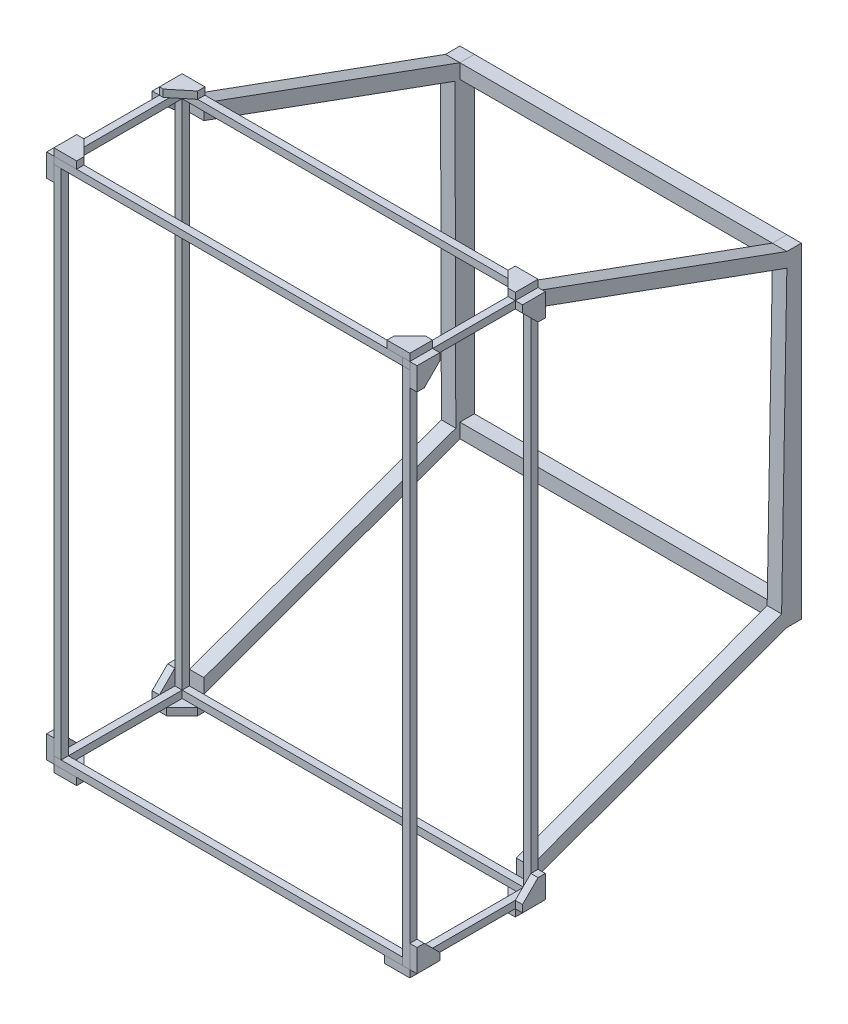
from build123d import *

# Parameters (mm, degrees)
SKETCH1_W                 = 6.35
SKETCH1_H                 = 6.35
BOSS_EXTRUDE1_DEPTH       = 100
SKETCH4_W                 = 6.35
SKETCH4_H                 = 6.35
BOSS_EXTRUDE3_DEPTH       = 450
BOSS_EXTRUDE3_DEPTH_BACK  = 6.35
SKETCH6_W                 = 6.35
SKETCH6_H                 = 6.378778746
BOSS_EXTRUDE4_DEPTH       = 100
SKETCH7_W                 = 6.35
SKETCH7_H                 = 6.35
BOSS_EXTRUDE5_DEPTH       = 300
BOSS_EXTRUDE5_DEPTH_BACK  = 6.35
SKETCH8_W                 = 6.35
SKETCH8_H                 = 6.378778746
BOSS_EXTRUDE6_DEPTH       = 300
BOSS_EXTRUDE6_DEPTH_BACK  = 6.35
SKETCH10_W                = 6.35
SKETCH10_H                = 6.35
BOSS_EXTRUDE7_DEPTH       = 450
BOSS_EXTRUDE7_DEPTH_BACK  = 6.378779
SKETCH12_W                = 6.35
SKETCH12_H                = 6.35
BOSS_EXTRUDE8_DEPTH       = 450
BOSS_EXTRUDE8_DEPTH_BACK  = 6.35
SKETCH16_W                = 6.35
SKETCH16_H                = 6.35
BOSS_EXTRUDE9_DEPTH       = 100
SKETCH20_W                = 6.35
SKETCH20_H                = 6.35
BOSS_EXTRUDE10_DEPTH      = 100
BOSS_EXTRUDE10_DEPTH_BACK = 6.35
SKETCH21_W                = 6.35
SKETCH21_H                = 6.378778746
BOSS_EXTRUDE11_DEPTH      = 300
BOSS_EXTRUDE11_DEPTH_BACK = 6.35
SKETCH22_W                = 6.35
SKETCH22_H                = 6.35
BOSS_EXTRUDE12_DEPTH      = 450
BOSS_EXTRUDE12_DEPTH_BACK = 6.35
SKETCH23_W                = 6.35
SKETCH23_H                = 6.35
BOSS_EXTRUDE13_DEPTH      = 300
BOSS_EXTRUDE13_DEPTH_BACK = 6.35
BOSS_EXTRUDE20_DEPTH      = 12.7
BOSS_EXTRUDE21_DEPTH      = 12.7
BOSS_EXTRUDE22_DEPTH      = 12.7
BOSS_EXTRUDE23_DEPTH      = 12.7
BOSS_EXTRUDE24_DEPTH      = 12.7
BOSS_EXTRUDE25_DEPTH      = 12.7
BOSS_EXTRUDE29_DEPTH      = 6.35
BOSS_EXTRUDE30_DEPTH      = 6.35
BOSS_EXTRUDE31_DEPTH      = 6.35
BOSS_EXTRUDE32_DEPTH      = 6.35
BOSS_EXTRUDE33_DEPTH      = 6.35
BOSS_EXTRUDE34_DEPTH      = 6.35
BOSS_EXTRUDE35_DEPTH      = 6.35
BOSS_EXTRUDE36_DEPTH      = 6.35
BOSS_EXTRUDE37_DEPTH      = 6.35
BOSS_EXTRUDE37_2_DEPTH    = 6.35
BOSS_EXTRUDE37_3_DEPTH    = 6.35
BOSS_EXTRUDE37_4_DEPTH    = 6.35
BOSS_EXTRUDE38_DEPTH      = 6.35
BOSS_EXTRUDE38_2_DEPTH    = 6.35
BOSS_EXTRUDE38_3_DEPTH    = 6.35
BOSS_EXTRUDE38_4_DEPTH    = 6.35
SKETCH43_W                = 274.6
SKETCH43_H                = 12.7
BOSS_EXTRUDE40_DEPTH      = 12.7
SKETCH44_W                = 274.6
SKETCH44_H                = 12.7
BOSS_EXTRUDE41_DEPTH      = 12.7


with BuildPart() as part:
    # Sketch1 → Boss-Extrude1 (new body)
    with BuildSketch(Plane.XY):
        with Locations((3.175, 3.175)):
            Rectangle(SKETCH1_W, SKETCH1_H)
    extrude(amount=BOSS_EXTRUDE1_DEPTH)


with BuildPart() as body_2:
    # Sketch4 → Boss-Extrude3 (new body, two sides)
    with BuildSketch(Plane(origin=(0, 0, 0), x_dir=(-1, 0, 0), z_dir=(0, -1, 0))) as boss_extrude3_sk:
        with Locations((-3.175, -103.175)):
            Rectangle(SKETCH4_W, SKETCH4_H)
    extrude(amount=BOSS_EXTRUDE3_DEPTH)
    extrude(boss_extrude3_sk.sketch, amount=-BOSS_EXTRUDE3_DEPTH_BACK)


with BuildPart() as body_3:
    # Sketch6 → Boss-Extrude4 (new body)
    with BuildSketch(Plane(origin=(0, 0, 100), x_dir=(-1, 0, 0), z_dir=(0, 0, -1))):
        with Locations((-3.175, -453.189389373)):
            Rectangle(SKETCH6_W, SKETCH6_H)
    extrude(amount=BOSS_EXTRUDE4_DEPTH)


with BuildPart() as body_4:
    # Sketch7 → Boss-Extrude5 (new body, two sides)
    with BuildSketch(Plane(origin=(6.35, 0, 0), x_dir=(0, 0, -1), z_dir=(1, 0, 0))) as boss_extrude5_sk:
        with Locations((-103.175, 3.175)):
            Rectangle(SKETCH7_W, SKETCH7_H)
    extrude(amount=BOSS_EXTRUDE5_DEPTH)
    extrude(boss_extrude5_sk.sketch, amount=-BOSS_EXTRUDE5_DEPTH_BACK)


with BuildPart() as body_5:
    # Sketch8 → Boss-Extrude6 (new body, two sides)
    with BuildSketch(Plane(origin=(6.35, 0, 0), x_dir=(0, 0, -1), z_dir=(1, 0, 0))) as boss_extrude6_sk:
        with Locations((-103.175, -453.189389373)):
            Rectangle(SKETCH8_W, SKETCH8_H)
    extrude(amount=BOSS_EXTRUDE6_DEPTH)
    extrude(boss_extrude6_sk.sketch, amount=-BOSS_EXTRUDE6_DEPTH_BACK)


with BuildPart() as body_6:
    # Sketch10 → Boss-Extrude7 (new body, two sides)
    with BuildSketch(Plane(origin=(0, -450, 0), x_dir=(1, 0, 0), z_dir=(0, 1, 0))) as boss_extrude7_sk:
        with Locations((309.525, -103.175)):
            Rectangle(SKETCH10_W, SKETCH10_H)
    extrude(amount=BOSS_EXTRUDE7_DEPTH)
    extrude(boss_extrude7_sk.sketch, amount=-BOSS_EXTRUDE7_DEPTH_BACK)


with BuildPart() as body_7:
    # Sketch12 → Boss-Extrude8 (new body, two sides)
    with BuildSketch(Plane(origin=(0, 0, 0), x_dir=(-1, 0, 0), z_dir=(0, -1, 0))) as boss_extrude8_sk:
        with Locations((-3.175, 3.175)):
            Rectangle(SKETCH12_W, SKETCH12_H)
    extrude(amount=BOSS_EXTRUDE8_DEPTH)
    extrude(boss_extrude8_sk.sketch, amount=-BOSS_EXTRUDE8_DEPTH_BACK)


with BuildPart() as body_8:
    # Sketch16 → Boss-Extrude9 (new body)
    with BuildSketch(Plane(origin=(0, 0, 100), x_dir=(-1, 0, 0), z_dir=(0, 0, -1))):
        with Locations((-309.525, -453.175)):
            Rectangle(SKETCH16_W, SKETCH16_H)
    extrude(amount=BOSS_EXTRUDE9_DEPTH)


with BuildPart() as body_9:
    # Sketch20 → Boss-Extrude10 (new body, two sides)
    with BuildSketch(Plane(origin=(0, 0, 100), x_dir=(-1, 0, 0), z_dir=(0, 0, -1))) as boss_extrude10_sk:
        with Locations((-309.525, 3.175)):
            Rectangle(SKETCH20_W, SKETCH20_H)
    extrude(amount=BOSS_EXTRUDE10_DEPTH)
    extrude(boss_extrude10_sk.sketch, amount=-BOSS_EXTRUDE10_DEPTH_BACK)


with BuildPart() as body_10:
    # Sketch21 → Boss-Extrude11 (new body, two sides)
    with BuildSketch(Plane(origin=(6.35, 0, 0), x_dir=(0, 0, -1), z_dir=(1, 0, 0))) as boss_extrude11_sk:
        with Locations((3.175, -453.189389373)):
            Rectangle(SKETCH21_W, SKETCH21_H)
    extrude(amount=BOSS_EXTRUDE11_DEPTH)
    extrude(boss_extrude11_sk.sketch, amount=-BOSS_EXTRUDE11_DEPTH_BACK)


with BuildPart() as body_11:
    # Sketch22 → Boss-Extrude12 (new body, two sides)
    with BuildSketch(Plane(origin=(0, -450, 0), x_dir=(1, 0, 0), z_dir=(0, 1, 0))) as boss_extrude12_sk:
        with Locations((309.525, 3.175)):
            Rectangle(SKETCH22_W, SKETCH22_H)
    extrude(amount=BOSS_EXTRUDE12_DEPTH)
    extrude(boss_extrude12_sk.sketch, amount=-BOSS_EXTRUDE12_DEPTH_BACK)


with BuildPart() as body_12:
    # Sketch23 → Boss-Extrude13 (new body, two sides)
    with BuildSketch(Plane.ZY.offset(-306.35)) as boss_extrude13_sk:
        with Locations((-3.175, 3.175)):
            Rectangle(SKETCH23_W, SKETCH23_H)
    extrude(amount=BOSS_EXTRUDE13_DEPTH)
    extrude(boss_extrude13_sk.sketch, amount=-BOSS_EXTRUDE13_DEPTH_BACK)


with BuildPart() as body_13:
    # Sketch25 → Boss-Extrude20 (new body)
    with BuildSketch(Plane(origin=(6.35, 0, 0), x_dir=(0, 0, -1), z_dir=(1, 0, 0))):
        Polygon((6.35, 0), (231.35, -81.89330271), (227.00634418, -93.827398994), (6.35, -13.51505771), align=None)
    extrude(amount=BOSS_EXTRUDE20_DEPTH)



with BuildPart() as body_14:
    # Sketch26 → Boss-Extrude21 (new body)
    with BuildSketch(Plane.ZY.offset(-306.35)):
        Polygon((-6.35, 0), (-231.35, -81.89330271), (-231.35, -94.59330271), (-6.35, -12.7), align=None)
    extrude(amount=BOSS_EXTRUDE21_DEPTH)



with BuildPart() as body_15:
    # Sketch27 → Boss-Extrude22 (new body)
    with BuildSketch(Plane.ZY.offset(-306.35)):
        Polygon((-6.35, -450), (-231.35, -368.10669729), (-226.727578025, -355.40669729), (-6.35, -437.3), align=None)
    extrude(amount=BOSS_EXTRUDE22_DEPTH)


with BuildPart() as body_16:
    # Sketch28 → Boss-Extrude23 (new body)
    with BuildSketch(Plane(origin=(6.35, 0, 0), x_dir=(0, 0, -1), z_dir=(1, 0, 0))):
        Polygon((6.35, -450), (231.35, -368.10669729), (227.760753861, -358.24532457), (6.35, -437.3), align=None)
    extrude(amount=BOSS_EXTRUDE23_DEPTH)


with BuildPart() as body_14_1:
    add(body_14.part)

    add(body_15.part)  # Boss-Extrude24 merges body 15
    # Sketch29 → Boss-Extrude24 (add)
    with BuildSketch(Plane(origin=(306.35, 0, 0), x_dir=(0, 0, -1), z_dir=(1, 0, 0))):
        Polygon((231.35, -81.89330271), (231.35, -94.59330271), (226.727578025, -355.40669729), (231.35, -368.10669729), (244.05, -368.10669729), (244.05, -81.89330271), align=None)
    extrude(amount=-BOSS_EXTRUDE24_DEPTH)


with BuildPart() as body_13_1:
    add(body_13.part)

    add(body_16.part)  # Boss-Extrude25 merges body 16
    # Sketch31 → Boss-Extrude25 (add)
    with BuildSketch(Plane.ZY.offset(-6.35)):
        Polygon((-231.35, -81.89330271), (-227.00634418, -93.827398994), (-227.760753861, -358.24532457), (-231.35, -368.10669729), (-244.05, -368.10669729), (-244.05, -81.89330271), align=None)
    extrude(amount=-BOSS_EXTRUDE25_DEPTH)


with BuildPart() as body_15_2:
    # Sketch32 → Boss-Extrude29 (new body)
    with BuildSketch(Plane(origin=(312.7, 0, 0), x_dir=(0, 0, -1), z_dir=(1, 0, 0))):
        Polygon((-106.35, 6.35), (-106.35, -13.65), (-100, -13.65), (-86.35, 0), (-86.35, 6.35), align=None)
    extrude(amount=BOSS_EXTRUDE29_DEPTH)


with BuildPart() as body_16_2:
    # Sketch33 → Boss-Extrude30 (new body)
    with BuildSketch(Plane(origin=(312.7, 0, 0), x_dir=(0, 0, -1), z_dir=(1, 0, 0))):
        Polygon((-106.35, -456.378778746), (-106.35, -436.378778746), (-100, -436.378778746), (-86.35, -450), (-86.35, -456.35), align=None)
    extrude(amount=BOSS_EXTRUDE30_DEPTH)


with BuildPart() as body_17:
    # Sketch34 → Boss-Extrude31 (new body)
    with BuildSketch(Plane(origin=(312.7, 0, 0), x_dir=(0, 0, -1), z_dir=(1, 0, 0))):
        Polygon((6.35, 6.35), (-13.65, 6.35), (-13.65, 0), (0, -13.65), (6.35, -13.65), align=None)
    extrude(amount=BOSS_EXTRUDE31_DEPTH)


with BuildPart() as body_18:
    # Sketch35 → Boss-Extrude32 (new body)
    with BuildSketch(Plane(origin=(312.7, 0, 0), x_dir=(0, 0, -1), z_dir=(1, 0, 0))):
        Polygon((6.35, -456.35), (-13.65, -456.35), (-13.65, -450), (0, -436.35), (6.35, -436.35), align=None)
    extrude(amount=BOSS_EXTRUDE32_DEPTH)


with BuildPart() as body_19:
    # Sketch36 → Boss-Extrude33 (new body)
    with BuildSketch(Plane.ZY):
        Polygon((106.35, 6.35), (106.35, -13.65), (100, -13.65), (86.35, 0), (86.35, 6.35), align=None)
    extrude(amount=BOSS_EXTRUDE33_DEPTH)


with BuildPart() as body_20:
    # Sketch38 → Boss-Extrude34 (new body)
    with BuildSketch(Plane.ZY):
        Polygon((106.35, -456.378778746), (106.35, -436.378778746), (100, -436.378778746), (86.35, -450), (86.35, -456.35), align=None)
    extrude(amount=BOSS_EXTRUDE34_DEPTH)


with BuildPart() as body_21:
    # Sketch39 → Boss-Extrude35 (new body)
    with BuildSketch(Plane.ZY):
        Polygon((-6.35, 6.35), (13.65, 6.35), (13.65, 0), (-2.247855025, -13.65), (-6.35, -13.65), align=None)
    extrude(amount=BOSS_EXTRUDE35_DEPTH)


with BuildPart() as body_22:
    # Sketch40 → Boss-Extrude36 (new body)
    with BuildSketch(Plane.ZY):
        Polygon((-6.35, -456.378778746), (13.65, -456.35), (13.65, -450), (0, -436.378778746), (-6.35, -436.378778746), align=None)
    extrude(amount=BOSS_EXTRUDE36_DEPTH)


with BuildPart() as body_23:
    # Sketch41 → Boss-Extrude37 (new body)
    with BuildSketch(Plane.XZ.offset(456.378778746)):
        Polygon((0, 106.35), (20, 106.35), (20, 100), (6.35, 86.35), (0, 86.35), align=None)
    extrude(amount=BOSS_EXTRUDE37_DEPTH)


with BuildPart() as body_24:
    # Sketch41 → Boss-Extrude37 2 (new body)
    with BuildSketch(Plane.XZ.offset(456.378778746)):
        Polygon((312.7, 106.35), (290.279780885, 106.35), (290.279780885, 100), (306.35, 83.929780885), (312.7, 83.929780885), align=None)
    extrude(amount=BOSS_EXTRUDE37_2_DEPTH)


with BuildPart() as body_25:
    # Sketch41 → Boss-Extrude37 3 (new body)
    with BuildSketch(Plane.XZ.offset(456.378778746)):
        Polygon((0, -6.35), (0, 13.65), (6.35, 13.65), (20, 0), (20, -6.35), align=None)
    extrude(amount=BOSS_EXTRUDE37_3_DEPTH)


with BuildPart() as body_26:
    # Sketch41 → Boss-Extrude37 4 (new body)
    with BuildSketch(Plane.XZ.offset(456.378778746)):
        Polygon((312.7, -6.35), (312.7, 13.65), (306.35, 13.65), (292.7, 0), (292.7, -6.35), align=None)
    extrude(amount=BOSS_EXTRUDE37_4_DEPTH)


with BuildPart() as body_27:
    # Sketch42 → Boss-Extrude38 (new body)
    with BuildSketch(Plane(origin=(0, 6.35, 0), x_dir=(1, 0, 0), z_dir=(0, 1, 0))):
        Polygon((0, 6.35), (20, 6.35), (20, 0), (3.319801498, -13.65), (0, -13.65), align=None)
    extrude(amount=BOSS_EXTRUDE38_DEPTH)


with BuildPart() as body_28:
    # Sketch42 → Boss-Extrude38 2 (new body)
    with BuildSketch(Plane(origin=(0, 6.35, 0), x_dir=(1, 0, 0), z_dir=(0, 1, 0))):
        Polygon((0, -106.35), (0, -86.35), (6.35, -86.35), (20, -100), (20, -106.35), align=None)
    extrude(amount=BOSS_EXTRUDE38_2_DEPTH)


with BuildPart() as body_29:
    # Sketch42 → Boss-Extrude38 3 (new body)
    with BuildSketch(Plane(origin=(0, 6.35, 0), x_dir=(1, 0, 0), z_dir=(0, 1, 0))):
        Polygon((312.7, -106.35), (312.7, -86.35), (306.35, -86.35), (292.7, -100), (292.7, -106.35), align=None)
    extrude(amount=BOSS_EXTRUDE38_3_DEPTH)


with BuildPart() as body_30:
    # Sketch42 → Boss-Extrude38 4 (new body)
    with BuildSketch(Plane(origin=(0, 6.35, 0), x_dir=(1, 0, 0), z_dir=(0, 1, 0))):
        Polygon((312.7, 6.35), (292.7, 6.35), (292.7, 0), (306.35, -13.65), (312.7, -13.65), align=None)
    extrude(amount=BOSS_EXTRUDE38_4_DEPTH)


with BuildPart() as body_31:
    # Sketch43 → Boss-Extrude40 (new body)
    with BuildSketch(Plane.XZ.offset(368.10669729)):
        with Locations((156.35, -237.7)):
            Rectangle(SKETCH43_W, SKETCH43_H)
    extrude(amount=-BOSS_EXTRUDE40_DEPTH)


with BuildPart() as body_32:
    # Sketch44 → Boss-Extrude41 (new body)
    with BuildSketch(Plane(origin=(0, -81.89330271, 0), x_dir=(1, 0, 0), z_dir=(0, 1, 0))):
        with Locations((156.35, 237.7)):
            Rectangle(SKETCH44_W, SKETCH44_H)
    extrude(amount=-BOSS_EXTRUDE41_DEPTH)


solid = Compound([part.part, body_2.part, body_3.part, body_4.part, body_5.part, body_6.part, body_7.part, body_8.part, body_9.part, body_10.part, body_11.part, body_12.part, body_14_1.part, body_13_1.part, body_15_2.part, body_16_2.part, body_17.part, body_18.part, body_19.part, body_20.part, body_21.part, body_22.part, body_23.part, body_24.part, body_25.part, body_26.part, body_27.part, body_28.part, body_29.part, body_30.part, body_31.part, body_32.part])
